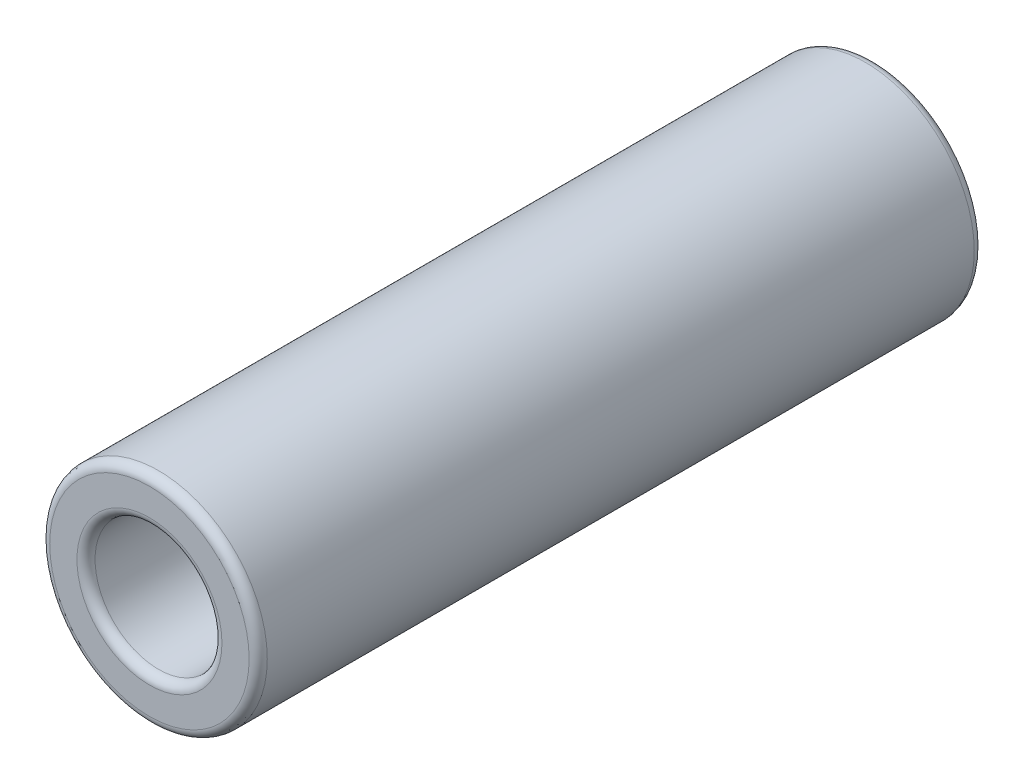
from build123d import *

# Parameters (mm, degrees)
SZKIC1_R                    = 6
SZKIC1_R_2                  = 3.5
DODANIE_WYCI_GNI_CIE1_DEPTH = 40
ZAOKR_GLENIE1_R             = 0.5


with BuildPart() as part:
    # Szkic1 → Dodanie-wyciągnięcie1 (new body)
    with BuildSketch(Plane.XY):
        Circle(SZKIC1_R)
        Circle(SZKIC1_R_2, mode=Mode.SUBTRACT)
    extrude(amount=DODANIE_WYCI_GNI_CIE1_DEPTH)

    # Zaokrąglenie1
    zaokr_glenie1_edges = [part.edges().sort_by_distance(p)[0] for p in [
        (-6, 0, 0),
        (-6, 0, 40),
        (-3.5, 0, 0),
        (-3.5, 0, 40),
    ]]
    fillet(zaokr_glenie1_edges, radius=ZAOKR_GLENIE1_R)


solid = part.part
